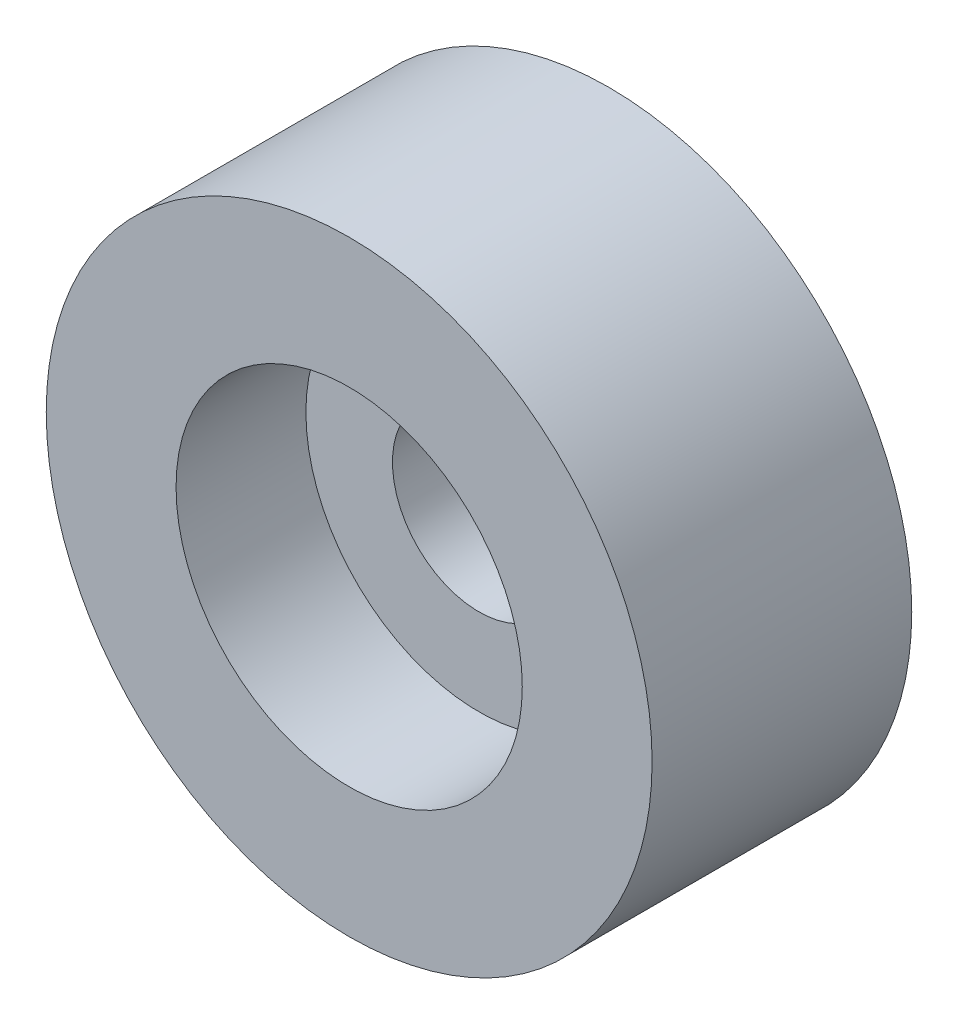
from build123d import *

# Parameters (mm, degrees)
SKETCH_1_R          = 3.5
SKETCH_1_R_2        = 1
EXTRUDE_1_DEPTH     = 3
SKETCH_2_R          = 2
CUT_EXTRUDE_1_DEPTH = 1.5


with BuildPart() as part:
    # 草图1 → 凸台-拉伸1 (new body)
    with BuildSketch(Plane.XY):
        Circle(SKETCH_1_R)
        Circle(SKETCH_1_R_2, mode=Mode.SUBTRACT)
    extrude(amount=EXTRUDE_1_DEPTH)

    # 草图2 → 切除-拉伸1 (cut)
    with BuildSketch(Plane.XY.offset(3)):
        Circle(SKETCH_2_R)
    extrude(amount=-CUT_EXTRUDE_1_DEPTH, mode=Mode.SUBTRACT)


solid = part.part
